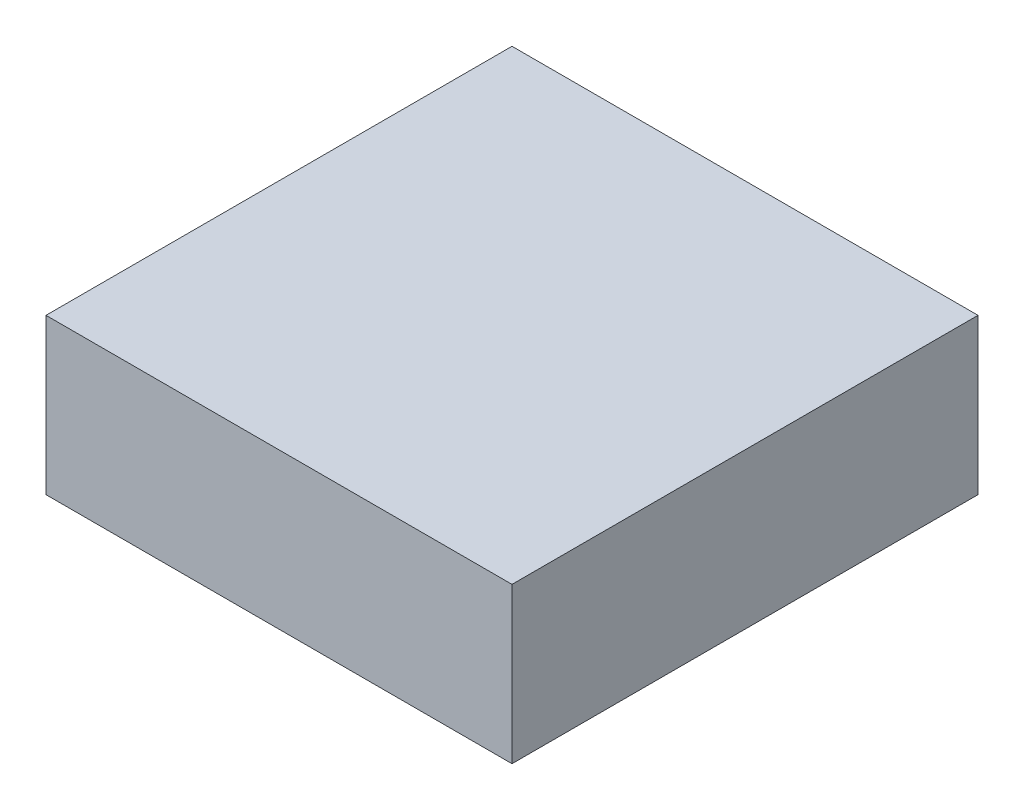
from build123d import *

# Parameters (mm, degrees)
CROQUIS1_W              = 15
CROQUIS1_H              = 15
SALIENTE_EXTRUIR1_DEPTH = 5


with BuildPart() as part:
    # Croquis1 → Saliente-Extruir1 (new body)
    with BuildSketch(Plane(origin=(0, 0, 0), x_dir=(1, 0, 0), z_dir=(0, 1, 0))):
        Rectangle(CROQUIS1_W, CROQUIS1_H)
    extrude(amount=SALIENTE_EXTRUIR1_DEPTH)


solid = part.part
